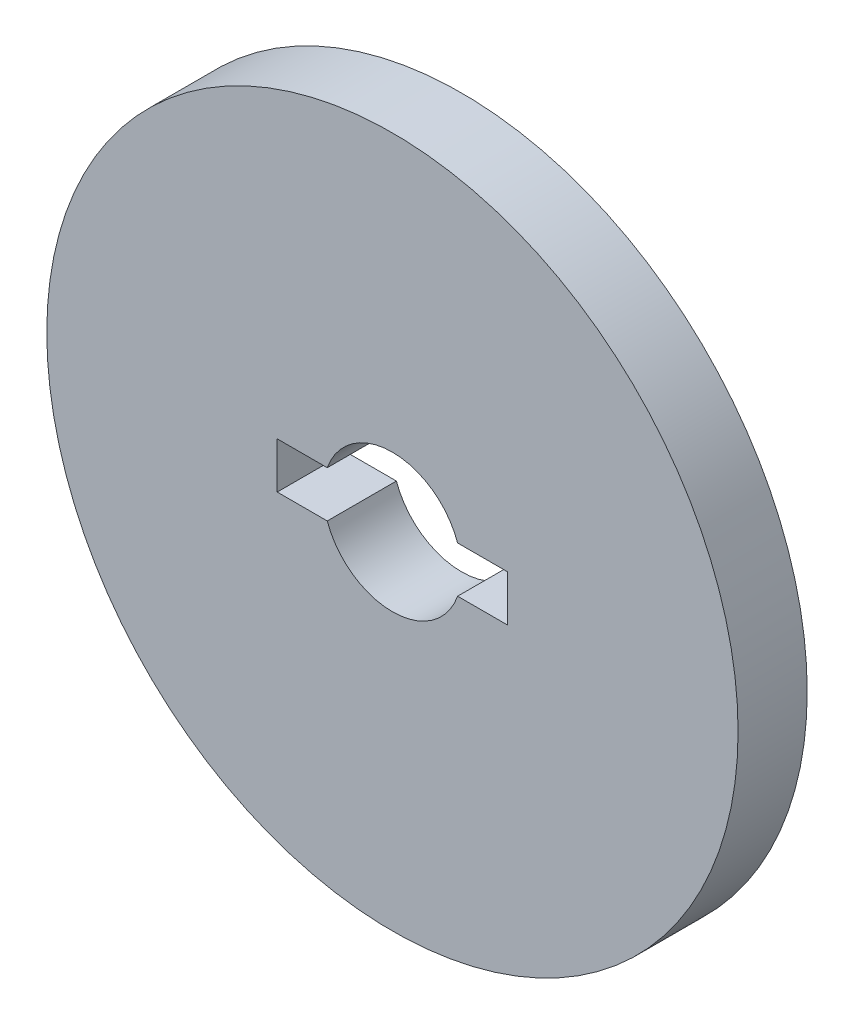
from build123d import *

# Parameters (mm, degrees)
SKETCH1_R           = 150
BOSS_EXTRUDE1_DEPTH = 30


with BuildPart() as part:
    # Sketch1 → Boss-Extrude1 (new body)
    with BuildSketch(Plane.XY):
        Circle(SKETCH1_R)
        with BuildLine():
            Line((-50, -10), (-50, 10))
            Line((-50, 10), (-28.284271247, 10))
            ThreePointArc((-28.284271247, 10), (0, 30), (28.284271247, 10))
            Line((28.284271247, 10), (50, 10))
            Line((50, 10), (50, -10))
            Line((50, -10), (28.284271247, -10))
            ThreePointArc((28.284271247, -10), (0, -30), (-28.284271247, -10))
            Line((-28.284271247, -10), (-50, -10))
        make_face(mode=Mode.SUBTRACT)
    extrude(amount=BOSS_EXTRUDE1_DEPTH)


solid = part.part
